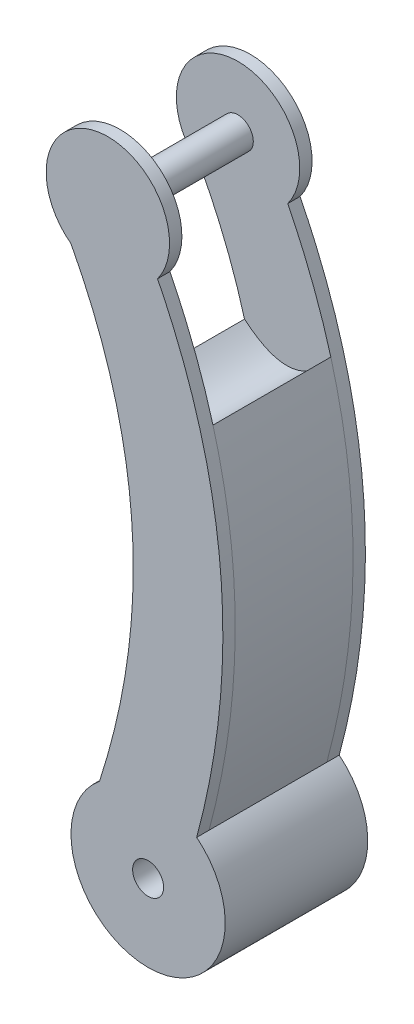
from build123d import *

# Parameters (mm, degrees)
SKETCH1_R                = 20
SKETCH1_R_2              = 25
BOSS_EXTRUDE1_DEPTH      = 4
BOSS_EXTRUDE2_DEPTH      = 19.1
SKETCH5_R                = 5.02
CUT_EXTRUDE1_DEPTH       = 49.2
SKETCH7_R                = 5
BOSS_EXTRUDE4_DEPTH      = 40.2
BOSS_EXTRUDE4_DEPTH_BACK = 2.2


with BuildPart() as part:
    # Sketch1 → Boss-Extrude1 (new body)
    with BuildSketch(Plane.XY):
        with Locations((-13.047428352, 181.745231989)):
            Circle(SKETCH1_R)
        with BuildLine():
            ThreePointArc((-15.752419285, 19.412915461), (0, 25), (15.752419285, 19.412915461))
            add(Edge.make_bspline(
                [(15.752419285, 19.412915461), (37.630116676, 100.741066361), (3.061753137, 169.892204032)],
                knots=[0, 0, 0, 1, 1, 1], degree=2))
            ThreePointArc((3.061753137, 169.892204032), (-10.099117092, 161.963739105), (-25, 165.709770319))
            add(Edge.make_bspline(
                [(-15.752419285, 19.412915461), (10.03237034, 99.240514814), (-25, 165.709770319)],
                knots=[0, 0, 0, 1, 1, 1], degree=2))
        make_face()
        Circle(SKETCH1_R_2)
    extrude(amount=BOSS_EXTRUDE1_DEPTH)

    # Sketch4 → Boss-Extrude2 (add)
    with BuildSketch(Plane.XY.offset(4)):
        with BuildLine():
            ThreePointArc((-15.752419292, 19.412915437), (1e-08, -24.999999987), (15.752419285, 19.412915461))
            add(Edge.make_bspline(
                [(15.752419285, 19.412915461), (32.045521078, 79.98089104), (17.031874688, 133.795114798)],
                knots=[0, 0, 0, 1, 1, 1], degree=2))
            add(Edge.make_bspline(
                [(-10.953146695, 130.455943826), (5.564580589, 116.540527234), (17.031874688, 133.795114798)],
                knots=[0, 0, 0, 1, 1, 1], degree=2))
            add(Edge.make_bspline(
                [(-10.953146695, 130.455943826), (3.367631556, 78.60702873), (-15.752419292, 19.412915437)],
                knots=[0, 0, 0, 1, 1, 1], degree=2))
        make_face()
    extrude(amount=BOSS_EXTRUDE2_DEPTH)

    # Mirror18: part across plane


with BuildPart() as part_1:
    add(part.part)
    add(part.part.mirror(Plane(origin=(4.301972293, 124.333028273, 23.1), x_dir=(1, 0, 0), z_dir=(0, 0, -1))))

    # Sketch5 → Cut-Extrude1 (cut)
    with BuildSketch(Plane.XY.offset(46.2)):
        Circle(SKETCH5_R)
    extrude(amount=-CUT_EXTRUDE1_DEPTH, mode=Mode.SUBTRACT)

    # Sketch7 → Boss-Extrude4 (add, two sides)
    with BuildSketch(Plane.XY.offset(4)) as boss_extrude4_sk:
        with Locations((-13.104058639, 181.741755044)):
            Circle(SKETCH7_R)
    extrude(amount=BOSS_EXTRUDE4_DEPTH)
    extrude(boss_extrude4_sk.sketch, amount=-BOSS_EXTRUDE4_DEPTH_BACK)


solid = part_1.part
